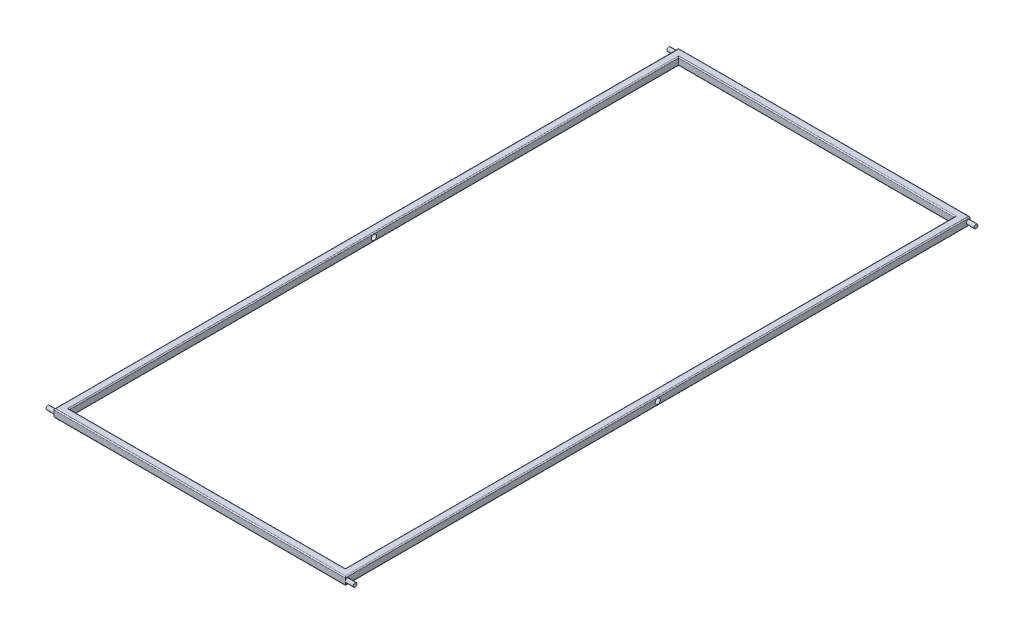
from build123d import *

# Parameters (mm, degrees)
CROQUIS1_W              = 560
CROQUIS1_H              = 1200
CROQUIS1_W_2            = 530
CROQUIS1_H_2            = 1170
SALIENTE_EXTRUIR1_DEPTH = 15
REDONDEO1_R             = 2
REDONDEO2_R             = 2
CROQUIS2_R              = 3.75
SALIENTE_EXTRUIR2_DEPTH = 15
CROQUIS3_R              = 5
CORTAR_EXTRUIR1_DEPTH   = 576
ESCALA1_SCALE           = 1.3


with BuildPart() as part:
    # Croquis1 → Saliente-Extruir1 (new body)
    with BuildSketch(Plane(origin=(0, 0, 0), x_dir=(1, 0, 0), z_dir=(0, 1, 0))):
        Rectangle(CROQUIS1_W, CROQUIS1_H)
        Rectangle(CROQUIS1_W_2, CROQUIS1_H_2, mode=Mode.SUBTRACT)
    extrude(amount=SALIENTE_EXTRUIR1_DEPTH)

    # Redondeo1
    redondeo1_edges = [part.edges().sort_by_distance(p)[0] for p in [
        (-280, 15, 0),
        (265, 15, 0),
        (0, 15, 600),
        (0, 15, -585),
        (-265, 15, 0),
        (0, 15, 585),
        (280, 15, 0),
        (0, 15, -600),
    ]]
    fillet(redondeo1_edges, radius=REDONDEO1_R)

    # Redondeo2
    redondeo2_edges = [part.edges().sort_by_distance(p)[0] for p in [
        (265, 0, 0),
        (0, 0, -585),
        (-265, 0, 0),
        (0, 0, 585),
        (0, 0, 600),
        (-280, 0, 0),
        (0, 0, -600),
        (280, 0, 0),
    ]]
    fillet(redondeo2_edges, radius=REDONDEO2_R)

    # Croquis2 → Saliente-Extruir2 (add)
    with BuildSketch(Plane.ZY.offset(280)):
        with Locations((596.25, 7.5)):
            Circle(CROQUIS2_R)
        with Locations((-596.25, 7.5)):
            Circle(CROQUIS2_R)
    saliente_extruir2 = extrude(amount=SALIENTE_EXTRUIR2_DEPTH)

    # Simetría1: Saliente-Extruir2 across plane
    add(saliente_extruir2.mirror(Plane(origin=(0, 0, 0), x_dir=(0, 0, 1), z_dir=(1, 0, 0))))

    # Croquis3 → Cortar-Extruir1 (cut, through all)
    with BuildSketch(Plane.ZY.offset(280)):
        with Locations((0, 7.5)):
            Circle(CROQUIS3_R)
    extrude(amount=-CORTAR_EXTRUIR1_DEPTH, mode=Mode.SUBTRACT)


with BuildPart() as part_1:
    # Escala1: scaled about (0, 0, 0)
    add(part.part.scale(ESCALA1_SCALE))


solid = part_1.part
